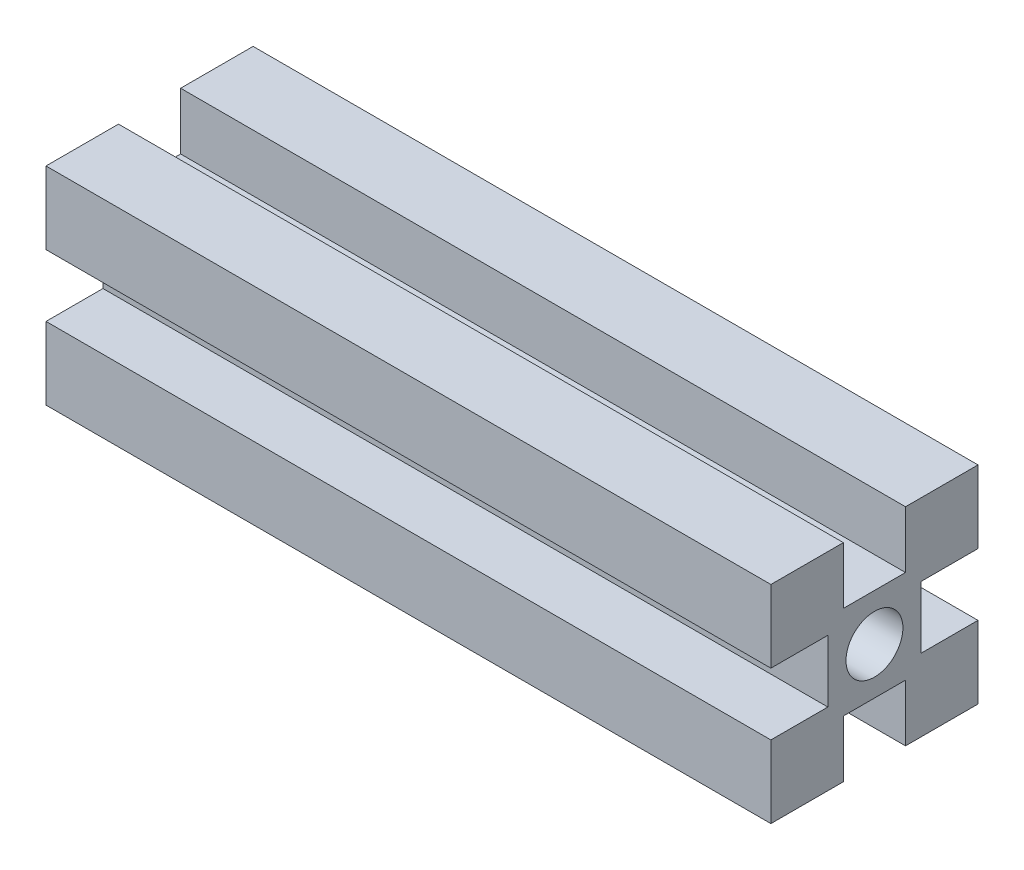
from build123d import *

# Parameters (mm, degrees)
ESQUISSE1_R        = 2.75
BOSS_EXTRU_1_DEPTH = 70


with BuildPart() as part:
    # Esquisse1 → Boss.-Extru.1 (new body)
    with BuildSketch(Plane(origin=(0, 0, 0), x_dir=(0, -1, 0), z_dir=(-1, 0, 0))):
        Polygon((-3, -10), (-3, -4.5), (3, -4.5), (3, -10), (10, -10), (10, -3), (4.5, -3), (4.5, 3), (10, 3), (10, 10), (3, 10), (3, 4.5), (-3, 4.5), (-3, 10), (-10, 10), (-10, 3), (-4.5, 3), (-4.5, -3), (-10, -3), (-10, -10), align=None)
        Circle(ESQUISSE1_R, mode=Mode.SUBTRACT)
    extrude(amount=-BOSS_EXTRU_1_DEPTH)


solid = part.part
